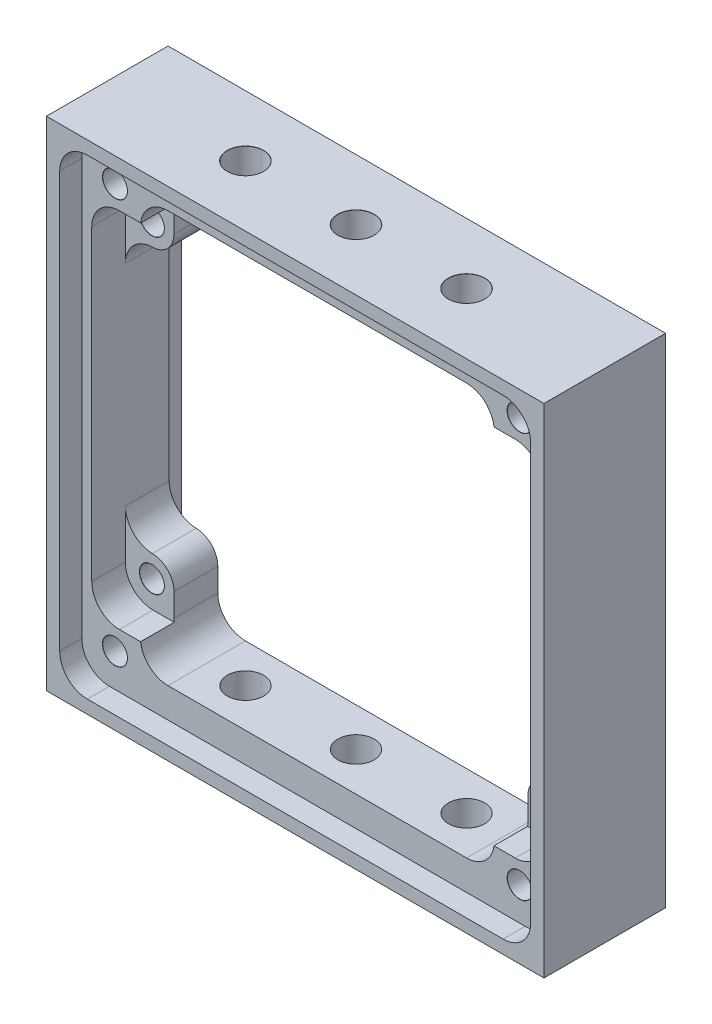
from build123d import *

# Parameters (mm, degrees)
SKETCH1_W_MOCK_PCB_W                      = 57.15
SKETCH1_W_MOCK_PCB_H                      = 57.15
BOSS_EXTRUDE1_DEPTH                       = 6.985
CUT_EXTRUDE1_DEPTH                        = 2.54
CUT_EXTRUDE3_DEPTH                        = 3.8608
F_4_40_TAPPED_HOLE1_AT_2_COUNT            = 2
F_4_40_TAPPED_HOLE1_AT_2_PITCH            = 45.72
F_4_40_TAPPED_HOLE1_AT_3_COUNT            = 2
F_4_40_TAPPED_HOLE1_AT_3_PITCH            = 35.56
F_4_40_TAPPED_HOLE1_AT_4_COUNT            = 2
F_4_40_TAPPED_HOLE1_AT_4_PITCH            = 57.920911595
F_4_40_TAPPED_HOLE2_AT_2_COUNT            = 2
F_4_40_TAPPED_HOLE2_AT_2_PITCH            = 46.482
F_4_40_TAPPED_HOLE2_AT_3_COUNT            = 2
F_4_40_TAPPED_HOLE2_AT_3_PITCH            = 65.735474806
F_4_40_TAPPED_HOLE2_AT_4_COUNT            = 2
F_4_40_TAPPED_HOLE2_AT_4_PITCH            = 46.482
F_8_32_TAPPED_HOLE1_D                     = 4.1656
F_8_32_TAPPED_HOLE1_DEPTH                 = 4.953
F_8_32_TAPPED_HOLE1_CSINK_D               = 4.191
F_8_32_TAPPED_HOLE1_CSINK_ANGLE           = 90
F_8_32_TAPPED_HOLE1_ON_FACE_2_D           = 4.1656
F_8_32_TAPPED_HOLE1_ON_FACE_2_DEPTH       = 4.953
F_8_32_TAPPED_HOLE1_ON_FACE_2_CSINK_D     = 4.191
F_8_32_TAPPED_HOLE1_ON_FACE_2_CSINK_ANGLE = 90


with BuildPart() as part:
    # Sketch1 w/mock PCB → Boss-Extrude1 (new body, symmetric)
    with BuildSketch(Plane.XY):
        Rectangle(SKETCH1_W_MOCK_PCB_W, SKETCH1_W_MOCK_PCB_H)
        with BuildLine():
            Line((20.32, 17.78), (20.32, 20.447))
            ThreePointArc((20.32, 20.447), (19.39006403, 22.69206403), (17.145, 23.622))
            Line((17.145, 23.622), (-17.145, 23.622))
            ThreePointArc((-17.145, 23.622), (-19.39006403, 22.69206403), (-20.32, 20.447))
            Line((-20.32, 20.447), (-20.32, 17.78))
            ThreePointArc((-20.32, 17.78), (-21.044102303, 16.004017017), (-22.803555556, 15.240627238))
            ThreePointArc((-22.803555556, 15.240627238), (-25.002872121, 14.286390014), (-25.908, 12.066411285))
            Line((-25.908, 12.066411285), (-25.908, -12.066411285))
            ThreePointArc((-25.908, -12.066411285), (-25.002872121, -14.286390014), (-22.803555556, -15.240627238))
            ThreePointArc((-22.803555556, -15.240627238), (-21.044102303, -16.004017017), (-20.32, -17.78))
            Line((-20.32, -17.78), (-20.32, -20.447))
            ThreePointArc((-20.32, -20.447), (-19.39006403, -22.69206403), (-17.145, -23.622))
            Line((-17.145, -23.622), (17.145, -23.622))
            ThreePointArc((17.145, -23.622), (19.39006403, -22.69206403), (20.32, -20.447))
            Line((20.32, -20.447), (20.32, -17.78))
            ThreePointArc((20.32, -17.78), (21.044102303, -16.004017017), (22.803555556, -15.240627238))
            ThreePointArc((22.803555556, -15.240627238), (25.002872121, -14.286390014), (25.908, -12.066411285))
            Line((25.908, -12.066411285), (25.908, 12.066411285))
            ThreePointArc((25.908, 12.066411285), (25.002872121, 14.286390014), (22.803555556, 15.240627238))
            ThreePointArc((22.803555556, 15.240627238), (21.044102303, 16.004017017), (20.32, 17.78))
        make_face(mode=Mode.SUBTRACT)
    extrude(amount=BOSS_EXTRUDE1_DEPTH, both=True)

    # Sketch2 → Cut-Extrude1 (cut)
    with BuildSketch(Plane.XY.offset(6.985)):
        with BuildLine():
            Line((-23.876, 27.051), (23.876, 27.051))
            ThreePointArc((23.876, 27.051), (26.12106403, 26.12106403), (27.051, 23.876))
            Line((27.051, 23.876), (27.051, -23.876))
            ThreePointArc((27.051, -23.876), (26.12106403, -26.12106403), (23.876, -27.051))
            Line((23.876, -27.051), (-23.876, -27.051))
            ThreePointArc((-23.876, -27.051), (-26.12106403, -26.12106403), (-27.051, -23.876))
            Line((-27.051, -23.876), (-27.051, 23.876))
            ThreePointArc((-27.051, 23.876), (-26.12106403, 26.12106403), (-23.876, 27.051))
        make_face()
    cut_extrude1 = extrude(amount=-CUT_EXTRUDE1_DEPTH, mode=Mode.SUBTRACT)

    # Mirror1: Cut-Extrude1 across plane
    add(cut_extrude1.mirror(Plane.XY), mode=Mode.SUBTRACT)

    # Sketch4 → Cut-Extrude3 (cut)
    with BuildSketch(Plane.XY.offset(4.445)):
        with BuildLine():
            Line((-20.32, 17.78), (-20.32, 20.447))
            ThreePointArc((-20.32, 20.447), (-20.314259086, 20.637845079), (-20.297057106, 20.828))
            Line((-20.297057106, 20.828), (-22.733, 20.828))
            ThreePointArc((-22.733, 20.828), (-24.97806403, 19.89806403), (-25.908, 17.653))
            Line((-25.908, 17.653), (-25.908, 12.066411285))
            ThreePointArc((-25.908, 12.066411285), (-25.002872121, 14.286390014), (-22.803555556, 15.240627238))
            ThreePointArc((-22.803555556, 15.240627238), (-21.044102303, 16.004017017), (-20.32, 17.78))
        make_face()
        with BuildLine():
            Line((25.908, -12.066411285), (25.908, -17.653))
            ThreePointArc((25.908, -17.653), (24.97806403, -19.89806403), (22.733, -20.828))
            Line((22.733, -20.828), (20.297057106, -20.828))
            ThreePointArc((20.297057106, -20.828), (20.314259086, -20.637845079), (20.32, -20.447))
            Line((20.32, -20.447), (20.32, -17.78))
            ThreePointArc((20.32, -17.78), (21.044102303, -16.004017017), (22.803555556, -15.240627238))
            ThreePointArc((22.803555556, -15.240627238), (25.002872121, -14.286390014), (25.908, -12.066411285))
        make_face()
        with BuildLine():
            Line((-25.908, -12.066411285), (-25.908, -17.653))
            ThreePointArc((-25.908, -17.653), (-24.97806403, -19.89806403), (-22.733, -20.828))
            Line((-22.733, -20.828), (-20.297057106, -20.828))
            ThreePointArc((-20.297057106, -20.828), (-20.314259086, -20.637845079), (-20.32, -20.447))
            Line((-20.32, -20.447), (-20.32, -17.78))
            ThreePointArc((-20.32, -17.78), (-21.044102303, -16.004017017), (-22.803555556, -15.240627238))
            ThreePointArc((-22.803555556, -15.240627238), (-25.002872121, -14.286390014), (-25.908, -12.066411285))
        make_face()
        with BuildLine():
            Line((20.297057106, 20.828), (22.733, 20.828))
            ThreePointArc((22.733, 20.828), (24.97806403, 19.89806403), (25.908, 17.653))
            Line((25.908, 17.653), (25.908, 12.066411285))
            ThreePointArc((25.908, 12.066411285), (25.002872121, 14.286390014), (22.803555556, 15.240627238))
            ThreePointArc((22.803555556, 15.240627238), (21.044102303, 16.004017017), (20.32, 17.78))
            Line((20.32, 17.78), (20.32, 20.447))
            ThreePointArc((20.32, 20.447), (20.314259086, 20.637845079), (20.297057106, 20.828))
        make_face()
    extrude(amount=-CUT_EXTRUDE3_DEPTH, mode=Mode.SUBTRACT)

    # Sketch11 → #4-40 Tapped Hole1 (revolve, cut)
    with BuildSketch(Plane(origin=(22.86, 17.78, 0.5842), x_dir=(0, -1, 0), z_dir=(1, 0, 0))):
        Polygon((0, 0), (0, 5.0292), (1.4351, 5.0292), (1.4224, 5.0165), (1.4224, 0.0127), (1.4351, 0), align=None)
    f_4_40_tapped_hole1 = revolve(axis=Axis((22.86, 17.78, 6.9342), (0, 0, -1)), mode=Mode.SUBTRACT)

    # #4-40 Tapped Hole1 at 2: #4-40 Tapped Hole1 ×2
    with Locations(*[(-i * F_4_40_TAPPED_HOLE1_AT_2_PITCH, 0, 0) for i in range(1, F_4_40_TAPPED_HOLE1_AT_2_COUNT)]):
        add(f_4_40_tapped_hole1, mode=Mode.SUBTRACT)

    # #4-40 Tapped Hole1 at 3: #4-40 Tapped Hole1 ×2
    with Locations(*[(0, -i * F_4_40_TAPPED_HOLE1_AT_3_PITCH, 0) for i in range(1, F_4_40_TAPPED_HOLE1_AT_3_COUNT)]):
        add(f_4_40_tapped_hole1, mode=Mode.SUBTRACT)

    # #4-40 Tapped Hole1 at 4: #4-40 Tapped Hole1 ×2
    with Locations(*[Vector(-0.789352217, -0.613940614, 0) * (i * F_4_40_TAPPED_HOLE1_AT_4_PITCH) for i in range(1, F_4_40_TAPPED_HOLE1_AT_4_COUNT)]):
        add(f_4_40_tapped_hole1, mode=Mode.SUBTRACT)

    # Sketch22 → #4-40 Tapped Hole2 (revolve, cut)
    with BuildSketch(Plane(origin=(-23.241, 23.241, 4.445), x_dir=(0, -1, 0), z_dir=(1, 0, 0))):
        Polygon((0, 0), (0, 8.89), (1.4351, 8.89), (1.4224, 8.8773), (1.4224, 0.0127), (1.4351, 0), align=None)
    f_4_40_tapped_hole2 = revolve(axis=Axis((-23.241, 23.241, 10.795), (0, 0, -1)), mode=Mode.SUBTRACT)

    # #4-40 Tapped Hole2 at 2: #4-40 Tapped Hole2 ×2
    with Locations(*[(i * F_4_40_TAPPED_HOLE2_AT_2_PITCH, 0, 0) for i in range(1, F_4_40_TAPPED_HOLE2_AT_2_COUNT)]):
        add(f_4_40_tapped_hole2, mode=Mode.SUBTRACT)

    # #4-40 Tapped Hole2 at 3: #4-40 Tapped Hole2 ×2
    with Locations(*[Vector(0.707106781, -0.707106781, 0) * (i * F_4_40_TAPPED_HOLE2_AT_3_PITCH) for i in range(1, F_4_40_TAPPED_HOLE2_AT_3_COUNT)]):
        add(f_4_40_tapped_hole2, mode=Mode.SUBTRACT)

    # #4-40 Tapped Hole2 at 4: #4-40 Tapped Hole2 ×2
    with Locations(*[(0, -i * F_4_40_TAPPED_HOLE2_AT_4_PITCH, 0) for i in range(1, F_4_40_TAPPED_HOLE2_AT_4_COUNT)]):
        add(f_4_40_tapped_hole2, mode=Mode.SUBTRACT)

    # #8-32 Tapped Hole1
    with Locations(Plane(origin=(-12.7, 28.575, 0), x_dir=(0, 0, 1), z_dir=(0, 1, 0))):
        with Locations((0, 0), (0, 25.4), (0, 12.7)):
            CounterSinkHole(F_8_32_TAPPED_HOLE1_D / 2, F_8_32_TAPPED_HOLE1_CSINK_D / 2, depth=F_8_32_TAPPED_HOLE1_DEPTH, counter_sink_angle=F_8_32_TAPPED_HOLE1_CSINK_ANGLE)

    # #8-32 Tapped Hole1 on face 2
    with Locations(Plane(origin=(12.7, -28.575, 0), x_dir=(0, 0, -1), z_dir=(0, -1, 0))):
        with Locations((0, 0), (0, -12.7), (0, -25.4)):
            CounterSinkHole(F_8_32_TAPPED_HOLE1_ON_FACE_2_D / 2, F_8_32_TAPPED_HOLE1_ON_FACE_2_CSINK_D / 2, depth=F_8_32_TAPPED_HOLE1_ON_FACE_2_DEPTH, counter_sink_angle=F_8_32_TAPPED_HOLE1_ON_FACE_2_CSINK_ANGLE)


solid = part.part
